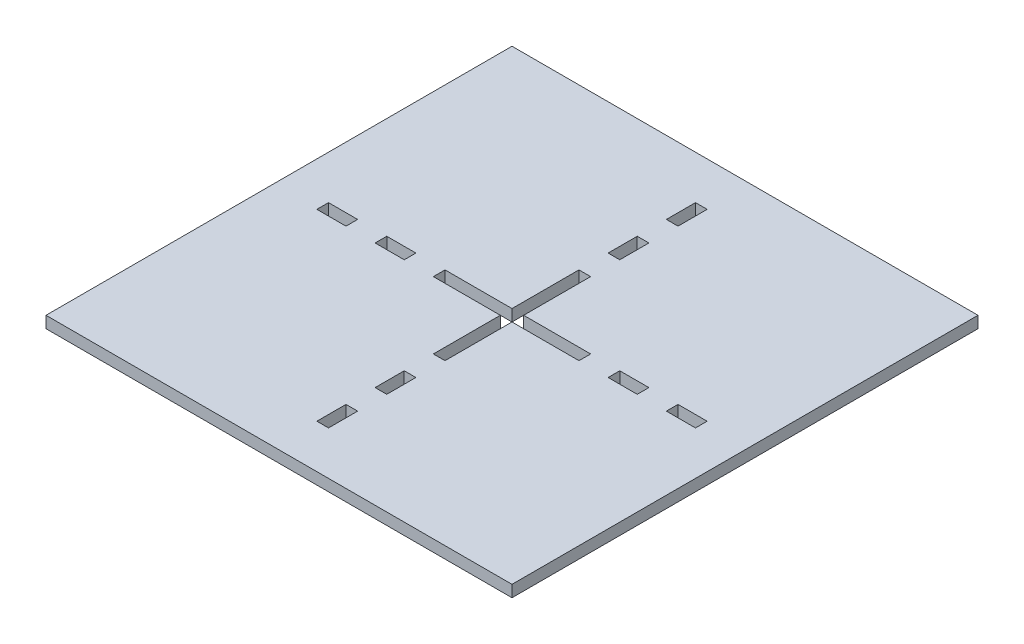
from build123d import *

# Parameters (mm, degrees)
SKETCH1_W           = 160
SKETCH1_H           = 160
BOSS_EXTRUDE1_DEPTH = 4
SKETCH2_W           = 4
SKETCH2_H           = 25
SKETCH2_H_2         = 10
CUT_EXTRUDE1_DEPTH  = 5
CIRPATTERN1_COUNT   = 4


with BuildPart() as part:
    # Sketch1 → Boss-Extrude1 (new body)
    with BuildSketch(Plane(origin=(0, 0, 0), x_dir=(1, 0, 0), z_dir=(0, 1, 0))):
        Rectangle(SKETCH1_W, SKETCH1_H)
    extrude(amount=BOSS_EXTRUDE1_DEPTH)

    # Sketch2 → Cut-Extrude1 (cut, through all)
    with BuildSketch(Plane(origin=(0, 4, 0), x_dir=(1, 0, 0), z_dir=(0, 1, 0))):
        with Locations((0, -12.5)):
            Rectangle(SKETCH2_W, SKETCH2_H)
        with Locations((0, -40)):
            Rectangle(SKETCH2_W, SKETCH2_H_2)
        with Locations((0, -60)):
            Rectangle(SKETCH2_W, SKETCH2_H_2)
    cut_extrude1 = extrude(amount=-CUT_EXTRUDE1_DEPTH, mode=Mode.SUBTRACT)

    # CirPattern1: Cut-Extrude1 ×4 about axis
    cirpattern1_axis = Axis((0, 0, 0), (0, 1, 0))
    for i in range(1, CIRPATTERN1_COUNT):
        add(cut_extrude1.rotate(cirpattern1_axis, i * 360 / CIRPATTERN1_COUNT), mode=Mode.SUBTRACT)


solid = part.part
